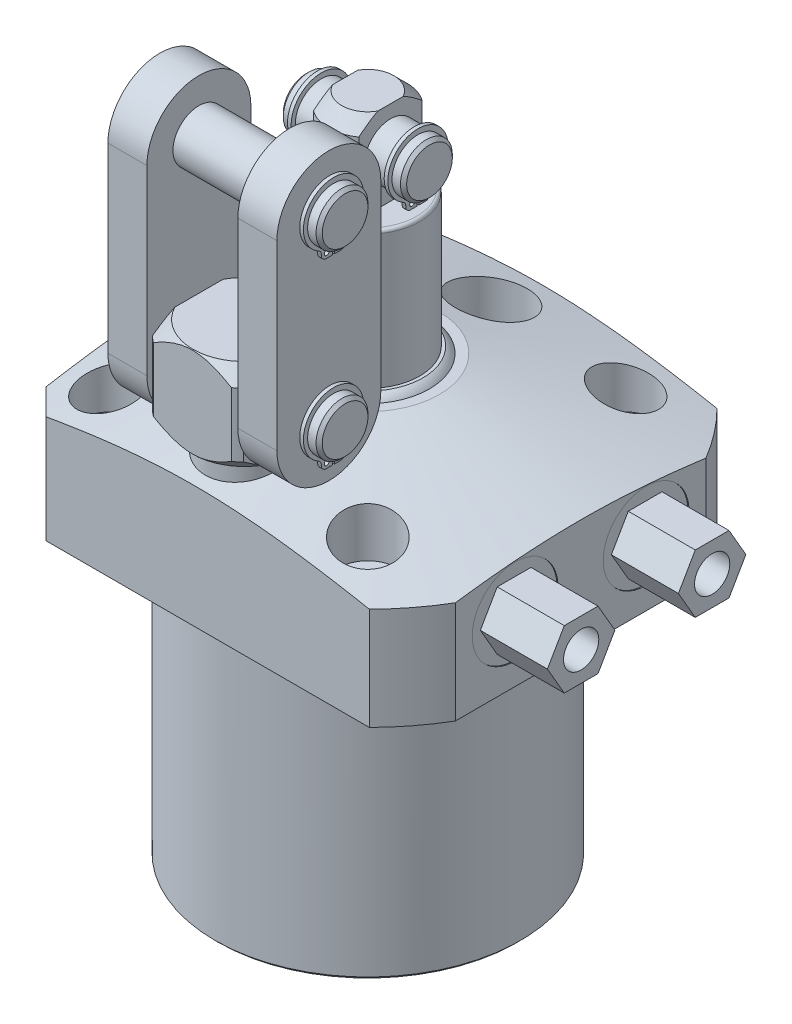
from build123d import *

# Parameters (mm, degrees)
SKETCH3_OUTSIDE_W          = 162.862
SKETCH3_OUTSIDE_H          = 162.862
SKETCH3_OUTSIDE_W_2        = 94.4626
SKETCH3_OUTSIDE_H_2        = 84.9376
CUT_EXTRUDE9_DEPTH         = 106.3498
CHAMFER8_SIZE              = 6.35
CHAMFER5_SIZE              = 0.762
HOLE1_D                    = 8.7376
HOLE1_DEPTH                = 36.4998
HOLE1_CBORE_D              = 14.2748
HOLE1_CBORE_DEPTH          = 17.4498
SKETCH34_R                 = 8.7503
CUT_EXTRUDE10_DEPTH        = 19.05
EXTRUDE14_DEPTH            = 16.383
HOLE2_D                    = 8.6106
HOLE2_DEPTH                = 6.7056
SKETCH33_R                 = 0.889
CUT_EXTRUDE7_DEPTH         = 20.6248
FILLET4_R                  = 0.762
SKETCH29_R                 = 6.3373
EXTRUDE11_DEPTH            = 15.0749
EXTRUDE2_START             = -2.8194
SKETCH16_R                 = 0.5969
EXTRUDE2_DEPTH             = 0.889
CHAMFER6_SIZE              = 0.762
CUT_EXTRUDE11_DEPTH        = 22.225
SKETCH30_R                 = 6.3373
EXTRUDE12_DEPTH            = 24.5999
EXTRUDE4_START             = -2.8194
SKETCH19_R                 = 0.5969
EXTRUDE4_DEPTH             = 0.889
EXTRUDE13_DEPTH            = 9.525
CHAMFER7_SIZE              = 0.762
LPATTERN2_COUNT            = 2
LPATTERN2_PITCH            = 44.45
LPATTERN2_START            = -2.8194
LPATTERN2_COPY_1_SKETCH_R  = 0.5969
LPATTERN2_COPY_1_DEPTH     = 0.889
CHAMFER7_OF_LPATTERN2_SIZE = 0.762


with BuildPart() as part:
    # Sketch28 → Revolve7 (revolve)
    with BuildSketch(Plane.XY, mode=Mode.PRIVATE) as revolve7_sk:
        Polygon((-17.4625, 36.4998), (-60.325, 25.014827739), (-60.325, 0), (-37.2999, 0), (-37.2999, -69.85), (0, -69.85), (0, 36.4998), align=None)
    revolve(revolve7_sk.sketch.rotate(Axis((0, 0, 0), (0, 1, 0)), 270), axis=Axis((0, 0, 0), (0, 1, 0)))  # turned: the seam where the file's is

    # Sketch3 outside → Cut-Extrude9 (cut)
    with BuildSketch(Plane(origin=(0, 36.4998, 0), x_dir=(-1, 0, 0), z_dir=(0, 1, 0))):
        Rectangle(SKETCH3_OUTSIDE_W, SKETCH3_OUTSIDE_H)
        with Locations((-4.7625, 0)):
            Rectangle(SKETCH3_OUTSIDE_W_2, SKETCH3_OUTSIDE_H_2, mode=Mode.SUBTRACT)
    extrude(amount=-CUT_EXTRUDE9_DEPTH, mode=Mode.SUBTRACT)

    # Chamfer8
    chamfer8_edges = [part.edges().sort_by_distance(p)[0] for p in [
        (-42.4688, 12.542923443, -42.4688),
        (-42.4688, 12.542923443, 42.4688),
    ]]
    chamfer(chamfer8_edges, length=CHAMFER8_SIZE)

    # Chamfer5
    chamfer5_edges = [part.edges().sort_by_distance(p)[0] for p in [
        (0, -69.85, 37.2999),
    ]]
    chamfer(chamfer5_edges, length=CHAMFER5_SIZE)

    # Hole1
    with Locations(Plane(origin=(0, 36.4998, 0), x_dir=(-1, 0, 0), z_dir=(0, 1, 0))):
        with Locations((-31.496, -31.496), (-31.496, 31.496), (31.496, -31.496), (31.496, 31.496)):
            CounterBoreHole(HOLE1_D / 2, HOLE1_CBORE_D / 2, HOLE1_CBORE_DEPTH, depth=HOLE1_DEPTH)

    # Sketch34 → Cut-Extrude10 (cut)
    with BuildSketch(Plane(origin=(0, 36.4998, 0), x_dir=(1, 0, 0), z_dir=(0, 1, 0))):
        with Locations(Location((0, 30.1498, 0), (0, 0, 270))):  # turned: the seam where the file's is
            Circle(SKETCH34_R)
        with Locations(Location((0, -30.1498, 0), (0, 0, 136.329694208))):  # turned: the seam where the file's is
            Circle(SKETCH34_R)
        with Locations(Location((-30.1498, 0, 0), (0, 0, 270))):  # turned: the seam where the file's is
            Circle(SKETCH34_R)
    extrude(amount=-CUT_EXTRUDE10_DEPTH, mode=Mode.SUBTRACT)

    # S2D0007 → Cut-Revolve2 (revolve, cut)
    with BuildSketch(Plane.XZ.offset(-15.875)):
        Polygon((51.9938, -16.002), (51.9938, -26.4795), (51.7398, -26.4795), (51.7398, -22.21865), (49.6697, -21.778636662), (48.871463338, -20.9804), (37.7698, -20.9804), (34.778475494, -16.002), align=None)
    cut_revolve2 = revolve(axis=Axis((-11.746808274, 15.875, -16.002), (-1, 0, 0)), mode=Mode.SUBTRACT)

    # Sketch6 → Cut-Revolve3 (revolve, cut)
    with BuildSketch(Plane.XY.offset(-16.002), mode=Mode.PRIVATE) as cut_revolve3_sk:
        with BuildLine():
            Line((50.67935, 0), (50.67935, 1.4478))
            Line((50.67935, 1.4478), (47.61885581, 1.4478))
            ThreePointArc((47.61885581, 1.4478), (46.937254622, 0.917608896), (46.1518, 0.5588))
            Line((46.1518, 0.5588), (45.0088, 0.5588))
            Line((45.0088, 0.5588), (45.0088, 0))
            Line((45.0088, 0), (50.67935, 0))
        make_face()
    cut_revolve3 = revolve(cut_revolve3_sk.sketch.rotate(Axis((45.0088, -21.049171587, -16.002), (0, 1, 0)), 90), axis=Axis((45.0088, -21.049171587, -16.002), (0, 1, 0)), mode=Mode.SUBTRACT)  # turned: the seam where the file's is

    # Sketch38 → Extrude14 (add)
    with BuildSketch(Plane(origin=(51.7398, 0, 0), x_dir=(0, 0, -1), z_dir=(1, 0, 0))):
        Polygon((24.243559623, 15.875), (20.122779811, 23.0124), (11.881220189, 23.0124), (7.760440377, 15.875), (11.881220189, 8.7376), (20.122779811, 8.7376), align=None)
    extrude14 = extrude(amount=EXTRUDE14_DEPTH)

    # Hole2
    with Locations(Plane(origin=(68.1228, 0, 0), x_dir=(0, 0, -1), z_dir=(1, 0, 0))):
        with Locations((16.002, 15.875)):
            hole2 = Hole(HOLE2_D / 2, depth=HOLE2_DEPTH)

    # Mirror6: Cut-Revolve2, Cut-Revolve3, Extrude14, Hole2 across plane
    add(cut_revolve2.mirror(Plane.XY), mode=Mode.SUBTRACT)
    add(cut_revolve3.mirror(Plane.XY), mode=Mode.SUBTRACT)
    add(extrude14.mirror(Plane.XY))
    add(hole2.mirror(Plane.XY), mode=Mode.SUBTRACT)

    # Sketch12 → Revolve2 (revolve)
    with BuildSketch(Plane(origin=(0, 0, 0), x_dir=(-1, 0, 0), z_dir=(0, 0, -1)), mode=Mode.PRIVATE) as revolve2_sk:
        with BuildLine():
            Line((0, 36.4998), (0, 38.0238))
            Line((0, 38.0238), (13.462, 38.0238))
            ThreePointArc((13.462, 38.0238), (14.358696206, 37.357310568), (15.0749, 36.4998))
            Line((15.0749, 36.4998), (0, 36.4998))
        make_face()
    revolve(revolve2_sk.sketch.rotate(Axis((0, 22.10562, 0), (0, 1, 0)), 270), axis=Axis((0, 22.10562, 0), (0, 1, 0)))  # turned: the seam where the file's is

    # Sketch13 → Revolve3 (revolve)
    with BuildSketch(Plane.XY, mode=Mode.PRIVATE) as revolve3_sk:
        Polygon((0, 38.0238), (0, 92.075), (6.35, 92.075), (9.525, 88.9), (9.525, 71.4502), (12.69365, 71.4502), (12.69365, 38.0238), align=None)
    revolve(revolve3_sk.sketch.rotate(Axis((0, 23.02637, 0), (0, 1, 0)), 90), axis=Axis((0, 23.02637, 0), (0, 1, 0)))  # turned: the seam where the file's is

    # Sketch14 → Cut-Extrude7 (cut)
    with BuildSketch(Plane(origin=(0, 92.075, 0), x_dir=(-1, 0, 0), z_dir=(0, 1, 0))):
        with BuildLine():
            Line((-5.5499, -7.741074537), (-5.5499, 7.741074537))
            ThreePointArc((-5.5499, 7.741074537), (-9.525, 0), (-5.5499, -7.741074537))
        make_face()
        with BuildLine():
            Line((5.5499, 7.741074537), (5.5499, -7.741074537))
            ThreePointArc((5.5499, -7.741074537), (9.525, 0), (5.5499, 7.741074537))
        make_face()
    extrude(amount=-CUT_EXTRUDE7_DEPTH, mode=Mode.SUBTRACT)

    # Fillet4
    fillet4_edges = [part.edges().sort_by_distance(p)[0] for p in [
        (0, 71.4502, 12.69365),
        (0, 71.4502, 9.525),
        (0, 71.4502, -9.525),
    ]]
    fillet(fillet4_edges, radius=FILLET4_R)

    # Sketch29 → Extrude11 (add, symmetric)
    with BuildSketch(Plane(origin=(0, 0, 0), x_dir=(0, 0, -1), z_dir=(1, 0, 0))):
        with Locations((0, 82.55)):
            Circle(SKETCH29_R)
    extrude(amount=EXTRUDE11_DEPTH, both=True)

    # Sketch16 → Extrude2 (add)
    with BuildSketch(Plane(origin=(15.0749, 52.3748, 0), x_dir=(0, 0, -1), z_dir=(1, 0, 0)).offset(EXTRUDE2_START)):
        with BuildLine():
            Line((0.23876, 24.236397543), (0.23876, 21.493197543))
            Line((0.23876, 21.493197543), (1.78816, 21.493197543))
            ThreePointArc((1.78816, 21.493197543), (2.632304075, 21.842853468), (2.98196, 22.686997543))
            Line((2.98196, 22.686997543), (2.98196, 22.931638033))
            ThreePointArc((2.98196, 22.931638033), (3.14610012, 23.535756375), (3.593383976, 23.973749643))
            ThreePointArc((3.593383976, 23.973749643), (0, 37.7698), (-3.593383976, 23.973749643))
            ThreePointArc((-3.593383976, 23.973749643), (-3.14610012, 23.535756375), (-2.98196, 22.931638033))
            Line((-2.98196, 22.931638033), (-2.98196, 22.686997543))
            ThreePointArc((-2.98196, 22.686997543), (-2.632304075, 21.842853468), (-1.78816, 21.493197543))
            Line((-1.78816, 21.493197543), (-0.23876, 21.493197543))
            Line((-0.23876, 21.493197543), (-0.23876, 24.236397543))
            ThreePointArc((-0.23876, 24.236397543), (0, 36.1188), (0.23876, 24.236397543))
        make_face()
        with Locations((1.43256, 22.686997543)):
            Circle(SKETCH16_R, mode=Mode.SUBTRACT)
        with Locations(Location((-1.43256, 22.686997543, 0), (0, 0, 180))):  # turned: the seam where the file's is
            Circle(SKETCH16_R, mode=Mode.SUBTRACT)
    extrude2 = extrude(amount=-EXTRUDE2_DEPTH)

    # Chamfer6
    chamfer6_edges = [part.edges().sort_by_distance(p)[0] for p in [
        (-15.0749, 82.55, 6.3373),
        (15.0749, 82.55, 6.3373),
    ]]
    chamfer(chamfer6_edges, length=CHAMFER6_SIZE)

    # Mirror2: Extrude2 across plane
    add(extrude2.mirror(Plane(origin=(0, 0, 0), x_dir=(0, 0, 1), z_dir=(1, 0, 0))))

    # Sketch35 → Revolve10 (revolve)
    with BuildSketch(Plane(origin=(0, 0, 0), x_dir=(0, 0, -1), z_dir=(1, 0, 0)), mode=Mode.PRIVATE) as revolve10_sk:
        Polygon((-30.1498, 17.4498), (-20.6248, 17.4498), (-20.6248, 36.4998), (-17.5768, 36.4998), (-14.2748, 39.8018), (-14.2748, 55.4228), (-17.5768, 58.7248), (-30.1498, 58.7248), align=None)
    revolve(revolve10_sk.sketch.rotate(Axis((0, 43.57409058, 30.1498), (0, -1, 0)), 180), axis=Axis((0, 43.57409058, 30.1498), (0, -1, 0)))  # turned: the seam where the file's is

    # Sketch36 → Cut-Extrude11 (cut)
    with BuildSketch(Plane(origin=(0, 58.7248, 0), x_dir=(1, 0, 0), z_dir=(0, 1, 0))):
        with BuildLine():
            Line((-11.1125, -41.48681763), (-11.1125, -18.81278237))
            ThreePointArc((-11.1125, -18.81278237), (-15.875, -30.1498), (-11.1125, -41.48681763))
        make_face()
        with BuildLine():
            Line((-9.525, -42.8498), (9.525, -42.8498))
            ThreePointArc((9.525, -42.8498), (0, -46.0248), (-9.525, -42.8498))
        make_face()
        with BuildLine():
            Line((11.1125, -41.48681763), (11.1125, -18.81278237))
            ThreePointArc((11.1125, -18.81278237), (15.875, -30.1498), (11.1125, -41.48681763))
        make_face()
        with BuildLine():
            Line((-9.525, -17.4498), (9.525, -17.4498))
            ThreePointArc((9.525, -17.4498), (0, -14.2748), (-9.525, -17.4498))
        make_face()
    extrude(amount=-CUT_EXTRUDE11_DEPTH, mode=Mode.SUBTRACT)

    # Sketch30 → Extrude12 (add, symmetric)
    with BuildSketch(Plane(origin=(0, 0, 0), x_dir=(0, 0, -1), z_dir=(1, 0, 0))):
        with Locations(Location((-30.1498, 47.625, 0), (0, 0, 90))):  # turned: the seam where the file's is
            Circle(SKETCH30_R)
    extrude12 = extrude(amount=EXTRUDE12_DEPTH, both=True)

    # Sketch19 → Extrude4 (add)
    with BuildSketch(Plane(origin=(24.5999, 11.0998, 22.225), x_dir=(0, 0, -1), z_dir=(1, 0, 0)).offset(EXTRUDE4_START)):
        with BuildLine():
            Line((-7.68604, 30.586397543), (-7.68604, 27.843197543))
            Line((-7.68604, 27.843197543), (-6.13664, 27.843197543))
            ThreePointArc((-6.13664, 27.843197543), (-5.292495925, 28.192853468), (-4.94284, 29.036997543))
            Line((-4.94284, 29.036997543), (-4.94284, 29.281638033))
            ThreePointArc((-4.94284, 29.281638033), (-4.77869988, 29.885756375), (-4.331416024, 30.323749643))
            ThreePointArc((-4.331416024, 30.323749643), (-7.9248, 44.1198), (-11.518183976, 30.323749643))
            ThreePointArc((-11.518183976, 30.323749643), (-11.07090012, 29.885756375), (-10.90676, 29.281638033))
            Line((-10.90676, 29.281638033), (-10.90676, 29.036997543))
            ThreePointArc((-10.90676, 29.036997543), (-10.557104075, 28.192853468), (-9.71296, 27.843197543))
            Line((-9.71296, 27.843197543), (-8.16356, 27.843197543))
            Line((-8.16356, 27.843197543), (-8.16356, 30.586397543))
            ThreePointArc((-8.16356, 30.586397543), (-7.9248, 42.4688), (-7.68604, 30.586397543))
        make_face()
        with Locations((-6.25348, 29.036997543)):
            Circle(SKETCH19_R, mode=Mode.SUBTRACT)
        with Locations(Location((-9.59612, 29.036997543, 0), (0, 0, 180))):  # turned: the seam where the file's is
            Circle(SKETCH19_R, mode=Mode.SUBTRACT)
    extrude4 = extrude(amount=-EXTRUDE4_DEPTH)

    # Sketch37 → Extrude13 (add)
    with BuildSketch(Plane(origin=(11.1125, 0, 0), x_dir=(0, 0, -1), z_dir=(1, 0, 0))):
        with BuildLine():
            Line((-42.849800117, 92.074999966), (-42.8498, 47.624999966))
            ThreePointArc((-42.8498, 47.624999966), (-30.149799966, 34.925), (-17.4498, 47.625000034))
            Line((-17.4498, 47.625000034), (-17.449800117, 92.075000034))
            ThreePointArc((-17.449800117, 92.075000034), (-30.149800151, 104.775), (-42.849800117, 92.074999966))
        make_face()
    extrude13 = extrude(amount=EXTRUDE13_DEPTH)

    # Mirror3: Extrude4 across plane
    add(extrude4.mirror(Plane(origin=(0, 0, 0), x_dir=(0, 0, 1), z_dir=(1, 0, 0))))

    # Chamfer7
    chamfer7_edges = [part.edges().sort_by_distance(p)[0] for p in [
        (-24.5999, 41.2877, 30.1498),
        (24.5999, 41.2877, 30.1498),
    ]]
    chamfer(chamfer7_edges, length=CHAMFER7_SIZE)

    # LPattern2: Extrude4, Extrude12 ×2
    with Locations(*[(0, i * LPATTERN2_PITCH, 0) for i in range(1, LPATTERN2_COUNT)]):
        add(extrude4)
        add(extrude12)

    # LPattern2 copy 1 sketch → LPattern2 copy 1 (add)
    with BuildSketch(Plane(origin=(-24.5999, 55.5498, 22.225000117), x_dir=(0, 0, -1), z_dir=(-1, 0, 0)).offset(LPATTERN2_START)):
        with BuildLine():
            Line((-7.68604, -30.586397543), (-7.68604, -27.843197543))
            Line((-7.68604, -27.843197543), (-6.13664, -27.843197543))
            ThreePointArc((-6.13664, -27.843197543), (-5.292495925, -28.192853468), (-4.94284, -29.036997543))
            Line((-4.94284, -29.036997543), (-4.94284, -29.281638033))
            ThreePointArc((-4.94284, -29.281638033), (-4.77869988, -29.885756375), (-4.331416024, -30.323749643))
            ThreePointArc((-4.331416024, -30.323749643), (-7.9248, -44.1198), (-11.518183976, -30.323749643))
            ThreePointArc((-11.518183976, -30.323749643), (-11.07090012, -29.885756375), (-10.90676, -29.281638033))
            Line((-10.90676, -29.281638033), (-10.90676, -29.036997543))
            ThreePointArc((-10.90676, -29.036997543), (-10.557104075, -28.192853468), (-9.71296, -27.843197543))
            Line((-9.71296, -27.843197543), (-8.16356, -27.843197543))
            Line((-8.16356, -27.843197543), (-8.16356, -30.586397543))
            ThreePointArc((-8.16356, -30.586397543), (-7.9248, -42.4688), (-7.68604, -30.586397543))
        make_face()
        with Locations((-6.25348, -29.036997543)):
            Circle(LPATTERN2_COPY_1_SKETCH_R, mode=Mode.SUBTRACT)
        with Locations((-9.59612, -29.036997543)):
            Circle(LPATTERN2_COPY_1_SKETCH_R, mode=Mode.SUBTRACT)
    extrude(amount=-LPATTERN2_COPY_1_DEPTH)

    # Chamfer7 of LPattern2
    chamfer7_of_lpattern2_edges = [part.edges().sort_by_distance(p)[0] for p in [
        (-24.5999, 85.7377, 30.149800117),
        (24.5999, 85.7377, 30.149800117),
    ]]
    chamfer(chamfer7_of_lpattern2_edges, length=CHAMFER7_OF_LPATTERN2_SIZE)

    # Mirror8: Extrude13 across plane
    add(extrude13.mirror(Plane(origin=(0, 0, 0), x_dir=(0, 0, 1), z_dir=(1, 0, 0))))


with BuildPart() as body_2:
    # Sketch33 → Revolve9 (revolve)
    with BuildSketch(Plane.XY.offset(-16.002), mode=Mode.PRIVATE) as revolve9_sk:
        with Locations((40.22725, 0.5842)):
            Circle(SKETCH33_R)
    revolve(revolve9_sk.sketch.rotate(Axis((45.0088, 8.329668034, -16.002), (0, -1, 0)), 90), axis=Axis((45.0088, 8.329668034, -16.002), (0, -1, 0)))  # turned: the seam where the file's is


with BuildPart() as body_3:
    # Mirror7: mirrored copy
    add(body_2.part.mirror(Plane.XY))


solid = Compound([part.part, body_2.part, body_3.part])
